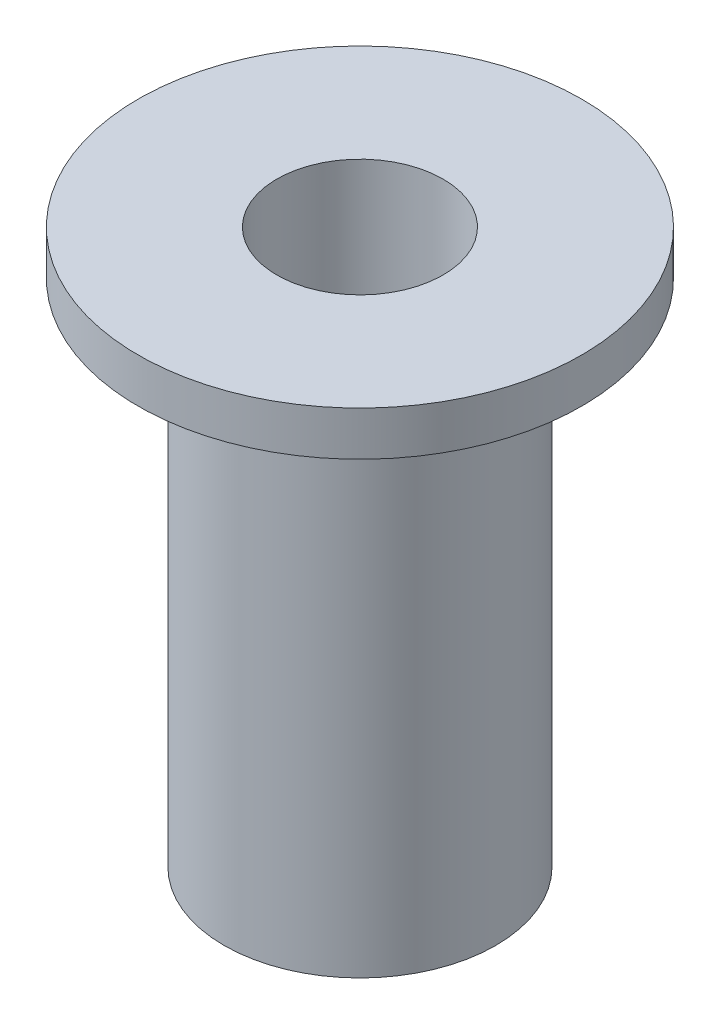
from build123d import *


with BuildPart() as part:
    # Sketch1 → Revolve1 (revolve)
    with BuildSketch(Plane.XY):
        Polygon((4, 10), (1.5, 10), (1.5, 0), (2.45, 0), (2.45, 9.2), (4, 9.2), align=None)
    revolve(axis=Axis((0, 0, 0), (0, 1, 0)))


solid = part.part
